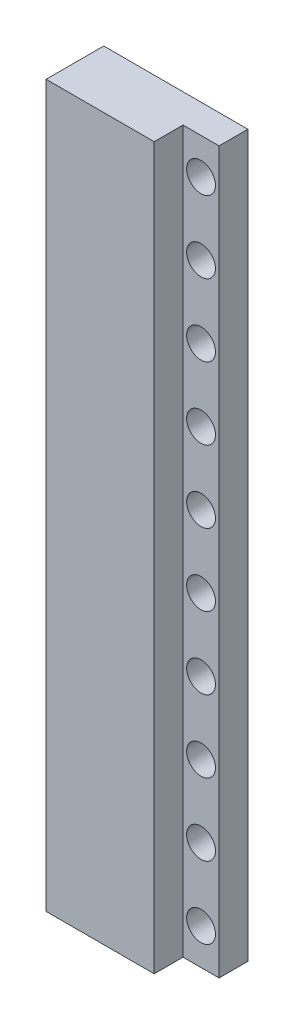
from build123d import *

# Parameters (mm, degrees)
SKETCH1_W           = 50
SKETCH1_H           = 250
BOSS_EXTRUDE2_DEPTH = 20
SKETCH1_4_W         = 50
SKETCH1_4_H         = 250
BOSS_EXTRUDE3_DEPTH = 10
SKETCH1_8_R         = 5
CUT_EXTRUDE7_DEPTH  = 20
CUT_EXTRUDE8_START  = -10
SKETCH4_W           = 12.5
SKETCH4_H           = 250
SKETCH4_R           = 5
CUT_EXTRUDE8_DEPTH  = 10


with BuildPart() as part:
    # Sketch1 → Boss-Extrude2 (new body)
    with BuildSketch(Plane.XY):
        with Locations((25, 125)):
            Rectangle(SKETCH1_W, SKETCH1_H)
    extrude(amount=BOSS_EXTRUDE2_DEPTH)

    # Sketch1_4 → Boss-Extrude3 (add)
    with BuildSketch(Plane.XY):
        with Locations((25, 125)):
            Rectangle(SKETCH1_4_W, SKETCH1_4_H)
    extrude(amount=BOSS_EXTRUDE3_DEPTH)

    # Sketch1_8 → Cut-Extrude7 (cut)
    with BuildSketch(Plane.XY):
        with Locations((43.75, 237.5)):
            Circle(SKETCH1_8_R)
        with Locations((43.75, 212.5)):
            Circle(SKETCH1_8_R)
        with Locations((43.75, 187.5)):
            Circle(SKETCH1_8_R)
        with Locations((43.75, 162.5)):
            Circle(SKETCH1_8_R)
        with Locations((43.75, 137.5)):
            Circle(SKETCH1_8_R)
        with Locations((43.75, 112.5)):
            Circle(SKETCH1_8_R)
        with Locations((43.75, 87.5)):
            Circle(SKETCH1_8_R)
        with Locations((43.75, 62.5)):
            Circle(SKETCH1_8_R)
        with Locations((43.75, 37.5)):
            Circle(SKETCH1_8_R)
        with Locations((43.75, 12.5)):
            Circle(SKETCH1_8_R)
    extrude(amount=CUT_EXTRUDE7_DEPTH, mode=Mode.SUBTRACT)

    # Sketch4 → Cut-Extrude8 (cut)
    with BuildSketch(Plane.XY.offset(20).offset(CUT_EXTRUDE8_START)):
        with Locations((43.75, 125)):
            Rectangle(SKETCH4_W, SKETCH4_H)
        with Locations((43.75, 12.5)):
            Circle(SKETCH4_R, mode=Mode.SUBTRACT)
        with Locations((43.75, 37.5)):
            Circle(SKETCH4_R, mode=Mode.SUBTRACT)
        with Locations((43.75, 62.5)):
            Circle(SKETCH4_R, mode=Mode.SUBTRACT)
        with Locations((43.75, 87.5)):
            Circle(SKETCH4_R, mode=Mode.SUBTRACT)
        with Locations((43.75, 112.5)):
            Circle(SKETCH4_R, mode=Mode.SUBTRACT)
        with Locations((43.75, 137.5)):
            Circle(SKETCH4_R, mode=Mode.SUBTRACT)
        with Locations((43.75, 162.5)):
            Circle(SKETCH4_R, mode=Mode.SUBTRACT)
        with Locations((43.75, 187.5)):
            Circle(SKETCH4_R, mode=Mode.SUBTRACT)
        with Locations((43.75, 212.5)):
            Circle(SKETCH4_R, mode=Mode.SUBTRACT)
        with Locations((43.75, 237.5)):
            Circle(SKETCH4_R, mode=Mode.SUBTRACT)
    extrude(amount=CUT_EXTRUDE8_DEPTH, mode=Mode.SUBTRACT)


solid = part.part
